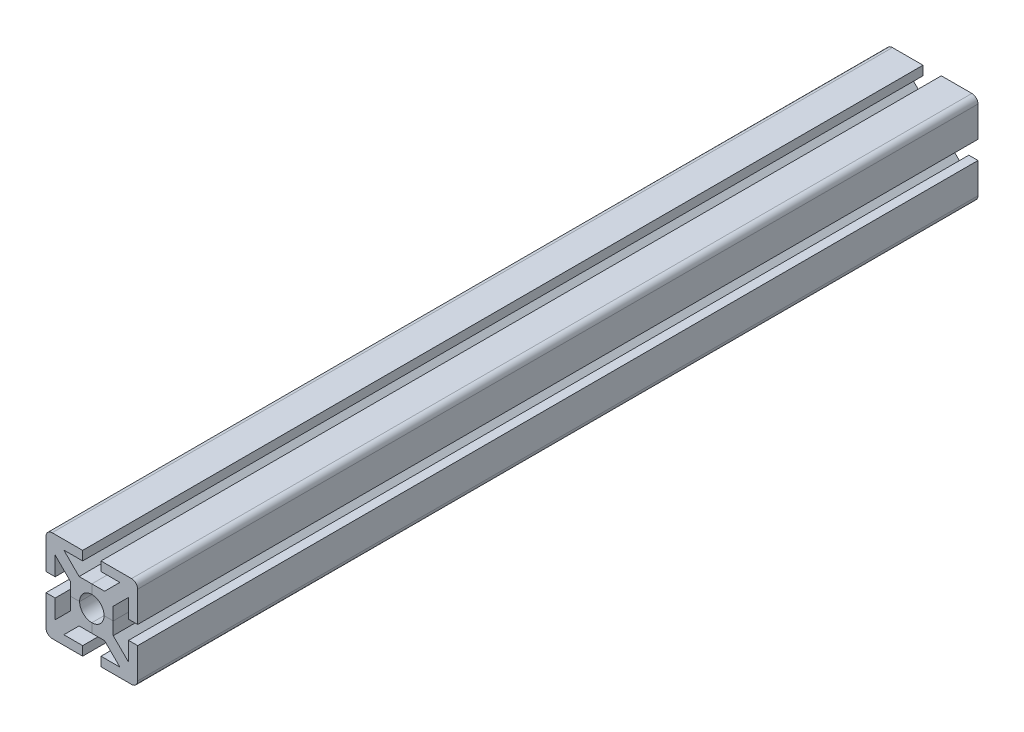
from build123d import *

# Parameters (mm, degrees)
SALIENTE_EXTRUIR1_DEPTH = 137.5
REDONDEO1_R             = 2
MATRIZC4_COUNT          = 4


with BuildPart() as part:
    # Croquis1 → Saliente-Extruir1 (new body, symmetric)
    with BuildSketch(Plane.XY):
        with BuildLine():
            Line((0, 4), (0, 7))
            Line((0, 7), (4.171572875, 7))
            Line((4.171572875, 7), (9.171572875, 12))
            Line((9.171572875, 12), (3, 12))
            Line((3, 12), (3, 15))
            Line((3, 15), (15, 15))
            Line((15, 15), (2.828427125, 2.828427125))
            ThreePointArc((2.828427125, 2.828427125), (1.530733729, 3.69551813), (0, 4))
        make_face()
    saliente_extruir1 = extrude(amount=SALIENTE_EXTRUIR1_DEPTH, both=True)

    # Simetría1: Saliente-Extruir1 across plane
    add(saliente_extruir1.mirror(Plane(origin=(2.828427125, 2.828427125, 137.5), x_dir=(0, 0, 1), z_dir=(-0.707106781, 0.707106781, 0))))

    # Redondeo1
    redondeo1_edges = [part.edges().sort_by_distance(p)[0] for p in [
        (15, 15, 0),
    ]]
    fillet(redondeo1_edges, radius=REDONDEO1_R)


with BuildPart() as matrizc4_1:
    # MatrizC4: pattern copy
    add(part.part.rotate(Axis((0, 0, 0), (0, 0, 1)), 1 * 360 / MATRIZC4_COUNT))


with BuildPart() as matrizc4_2:
    # MatrizC4: pattern copy
    add(part.part.rotate(Axis((0, 0, 0), (0, 0, 1)), 2 * 360 / MATRIZC4_COUNT))


with BuildPart() as matrizc4_3:
    # MatrizC4: pattern copy
    add(part.part.rotate(Axis((0, 0, 0), (0, 0, 1)), 3 * 360 / MATRIZC4_COUNT))


solid = Compound([part.part, matrizc4_1.part, matrizc4_2.part, matrizc4_3.part])
